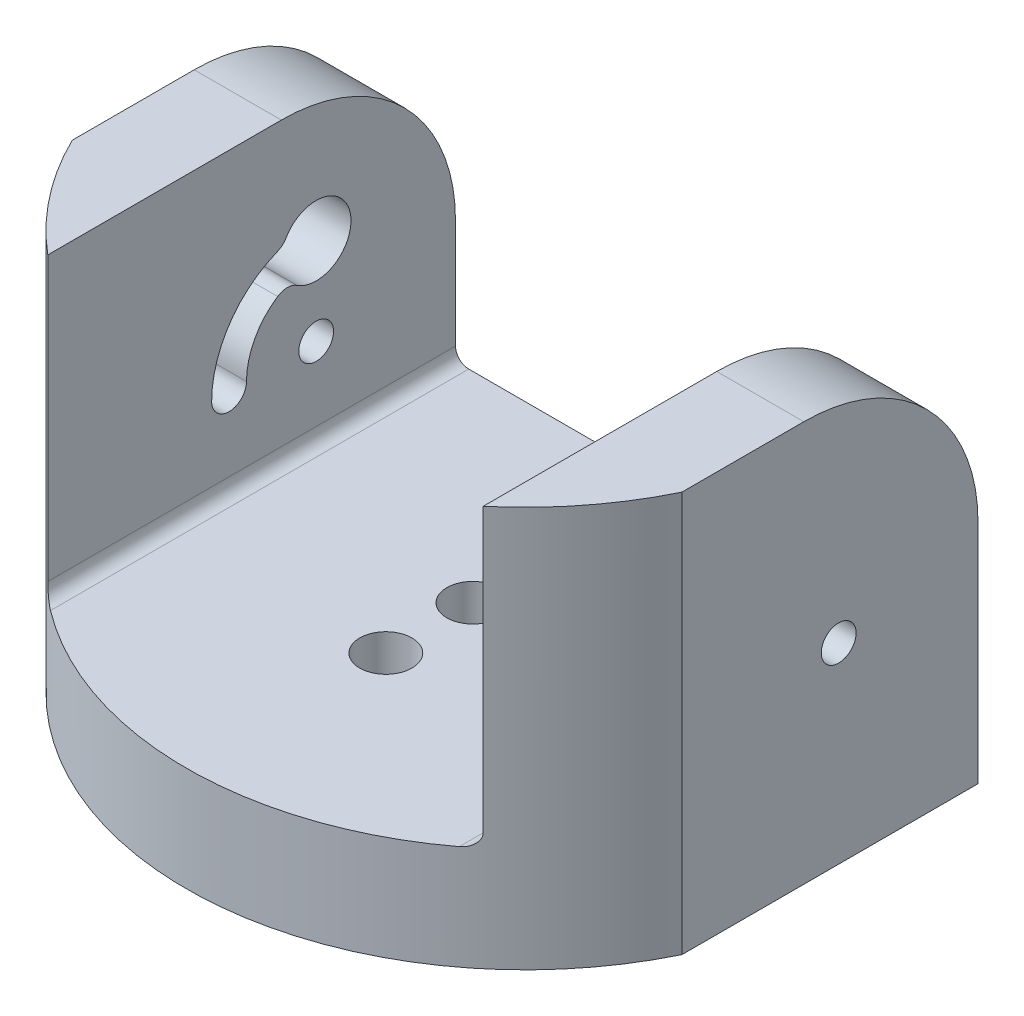
from build123d import *

# Parameters (mm, degrees)
SKETCH1_W           = 35
SKETCH1_H           = 45
BOSS_EXTRUDE1_DEPTH = 6
SKETCH2_W           = 45
SKETCH2_H           = 17
BOSS_EXTRUDE2_DEPTH = 5
SKETCH3_R           = 1
CUT_EXTRUDE1_DEPTH  = 5
SKETCH3_2_R         = 1
CUT_EXTRUDE2_DEPTH  = 30
SKETCH4_R           = 2
CUT_EXTRUDE3_DEPTH  = 5
FILLET1_R           = 0.762
FILLET2_R           = 10
FILLET3_R           = 1
CUT_EXTRUDE4_DEPTH  = 23
SKETCH6_R           = 1.5
CUT_EXTRUDE5_DEPTH  = 6


with BuildPart() as part:
    # Sketch1 → Boss-Extrude1 (new body)
    with BuildSketch(Plane(origin=(0, 0, 0), x_dir=(1, 0, 0), z_dir=(0, 1, 0))):
        Rectangle(SKETCH1_W, SKETCH1_H)
    extrude(amount=BOSS_EXTRUDE1_DEPTH)

    # Sketch2 → Boss-Extrude2 (add)
    with BuildSketch(Plane.ZY.offset(17.5)):
        with Locations((0, 14.5)):
            Rectangle(SKETCH2_W, SKETCH2_H)
    boss_extrude2 = extrude(amount=-BOSS_EXTRUDE2_DEPTH)

    # Mirror1: Boss-Extrude2 across plane
    add(boss_extrude2.mirror(Plane(origin=(0, 0, 0), x_dir=(0, 0, 1), z_dir=(1, 0, 0))))

    # Sketch3 → Cut-Extrude1 (cut)
    with BuildSketch(Plane(origin=(-12.5, 0, 0), x_dir=(0, 0, -1), z_dir=(1, 0, 0))):
        with Locations((14.5, 11)):
            Circle(SKETCH3_R)
        with BuildLine():
            ThreePointArc((14.5, 17), (10.257359313, 15.242640687), (8.5, 11))
            ThreePointArc((8.5, 11), (9.5, 10), (10.5, 11))
            ThreePointArc((10.5, 11), (11.671572875, 13.828427125), (14.5, 15))
            ThreePointArc((14.5, 15), (15.5, 16), (14.5, 17))
        make_face()
    extrude(amount=-CUT_EXTRUDE1_DEPTH, mode=Mode.SUBTRACT)

    # Sketch3_2 → Cut-Extrude2 (cut)
    with BuildSketch(Plane(origin=(-12.5, 0, 0), x_dir=(0, 0, -1), z_dir=(1, 0, 0))):
        with Locations((14.5, 11)):
            Circle(SKETCH3_2_R)
    extrude(amount=CUT_EXTRUDE2_DEPTH, mode=Mode.SUBTRACT)

    # Sketch4 → Cut-Extrude3 (cut)
    with BuildSketch(Plane.ZY.offset(17.5)):
        with Locations((-14.5, 16)):
            Circle(SKETCH4_R)
    extrude(amount=-CUT_EXTRUDE3_DEPTH, mode=Mode.SUBTRACT)

    # Fillet1
    fillet1_edges = [part.edges().sort_by_distance(p)[0] for p in [
        (-12.5, 6, 0),
        (12.5, 6, 0),
    ]]
    fillet(fillet1_edges, radius=FILLET1_R)

    # Fillet2
    fillet2_edges = [part.edges().sort_by_distance(p)[0] for p in [
        (-15, 23, -22.5),
        (-15, 23, 22.5),
        (15, 23, 22.5),
        (15, 23, -22.5),
    ]]
    fillet(fillet2_edges, radius=FILLET2_R)

    # Fillet3
    fillet3_edges = [part.edges().sort_by_distance(p)[0] for p in [
        (-15, 16.7, -12.6265006),
        (-15, 14.7, -12.980131585),
    ]]
    fillet(fillet3_edges, radius=FILLET3_R)

    # Sketch5 → Cut-Extrude4 (cut)
    with BuildSketch(Plane.XZ):
        with BuildLine():
            Line((17.5, 22.5), (17.5, -5.5))
            ThreePointArc((17.5, -5.5), (0, 5.455076458), (-17.5, -5.5))
            Line((-17.5, -5.5), (-17.5, 22.5))
            Line((-17.5, 22.5), (17.5, 22.5))
        make_face()
    extrude(amount=-CUT_EXTRUDE4_DEPTH, mode=Mode.SUBTRACT)

    # Sketch6 → Cut-Extrude5 (cut)
    with BuildSketch(Plane(origin=(0, 6, 0), x_dir=(1, 0, 0), z_dir=(0, 1, 0))):
        with Locations((0, 11)):
            Circle(SKETCH6_R)
        with Locations((0, 6)):
            Circle(SKETCH6_R)
    extrude(amount=-CUT_EXTRUDE5_DEPTH, mode=Mode.SUBTRACT)


solid = part.part
